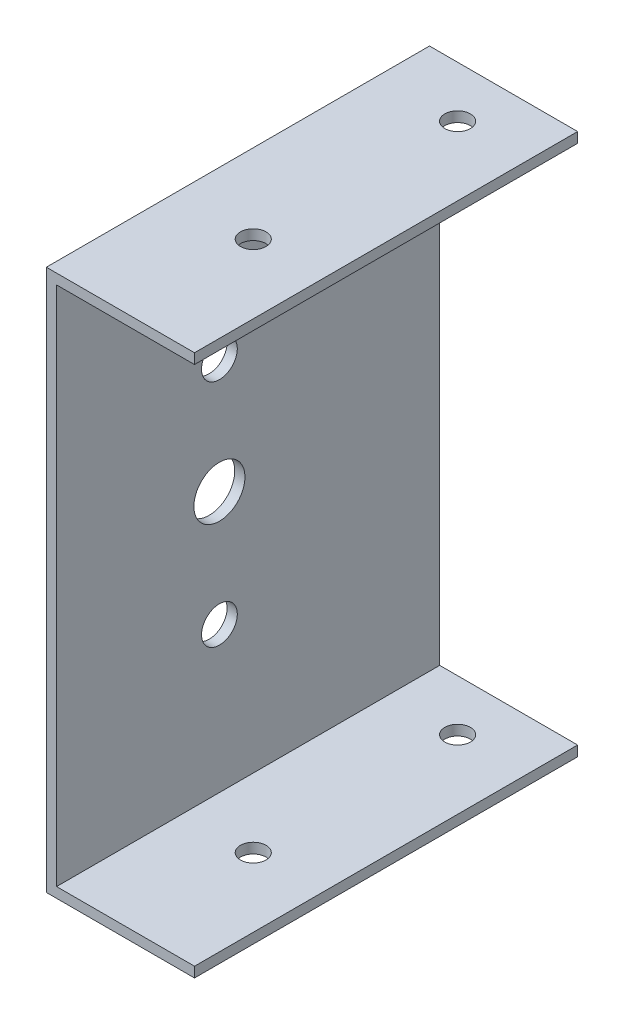
from build123d import *

# Parameters (mm, degrees)
ESBO_O1_W                  = 27
ESBO_O1_H                  = 75
RESSALTO_EXTRUS_O1_DEPTH   = 2
ESBO_O2_W                  = 75
ESBO_O2_H                  = 104
RESSALTO_EXTRUS_O2_DEPTH   = 2
ESBO_O3_W                  = 29
ESBO_O3_H                  = 75
RESSALTO_EXTRUS_O3_DEPTH   = 2
ESBO_O4_R                  = 5
CORTE_EXTRUS_O1_DEPTH      = 2
ESBO_O5_R                  = 2.5
CORTE_EXTRUS_O2_DEPTH      = 1
CORTE_EXTRUS_O2_DEPTH_BACK = 107
ESBO_O7_R                  = 3.5
CORTE_EXTRUS_O3_DEPTH      = 10


with BuildPart() as part:
    # Esboço1 → Ressalto-extrusão1 (new body)
    with BuildSketch(Plane(origin=(0, 0, 0), x_dir=(1, 0, 0), z_dir=(0, 1, 0))):
        Rectangle(ESBO_O1_W, ESBO_O1_H)
    extrude(amount=RESSALTO_EXTRUS_O1_DEPTH)

    # Esboço2 → Ressalto-extrusão2 (add)
    with BuildSketch(Plane.ZY.offset(13.5)):
        with Locations((0, 52)):
            Rectangle(ESBO_O2_W, ESBO_O2_H)
    extrude(amount=RESSALTO_EXTRUS_O2_DEPTH)

    # Esboço3 → Ressalto-extrusão3 (add)
    with BuildSketch(Plane(origin=(0, 104, 0), x_dir=(1, 0, 0), z_dir=(0, 1, 0))):
        with Locations((-1, 0)):
            Rectangle(ESBO_O3_W, ESBO_O3_H)
    extrude(amount=RESSALTO_EXTRUS_O3_DEPTH)

    # Esboço4 → Corte-extrusão1 (cut)
    with BuildSketch(Plane.ZY.offset(15.5)):
        with Locations((5.625, 53)):
            Circle(ESBO_O4_R)
    extrude(amount=-CORTE_EXTRUS_O1_DEPTH, mode=Mode.SUBTRACT)

    # Esboço5 → Corte-extrusão2 (cut, two sides)
    with BuildSketch(Plane(origin=(0, 106, 0), x_dir=(1, 0, 0), z_dir=(0, 1, 0))) as corte_extrus_o2_sk:
        with Locations((0, 27.5)):
            Circle(ESBO_O5_R)
        with Locations((0, -12.5)):
            Circle(ESBO_O5_R)
    extrude(amount=CORTE_EXTRUS_O2_DEPTH, mode=Mode.SUBTRACT)
    extrude(corte_extrus_o2_sk.sketch, amount=-CORTE_EXTRUS_O2_DEPTH_BACK, mode=Mode.SUBTRACT)

    # Esboço7 → Corte-extrusão3 (cut)
    with BuildSketch(Plane.ZY.offset(15.5)):
        with Locations((5.625, 75.5)):
            Circle(ESBO_O7_R)
        with Locations((5.625, 30.5)):
            Circle(ESBO_O7_R)
    extrude(amount=-CORTE_EXTRUS_O3_DEPTH, mode=Mode.SUBTRACT)


solid = part.part
